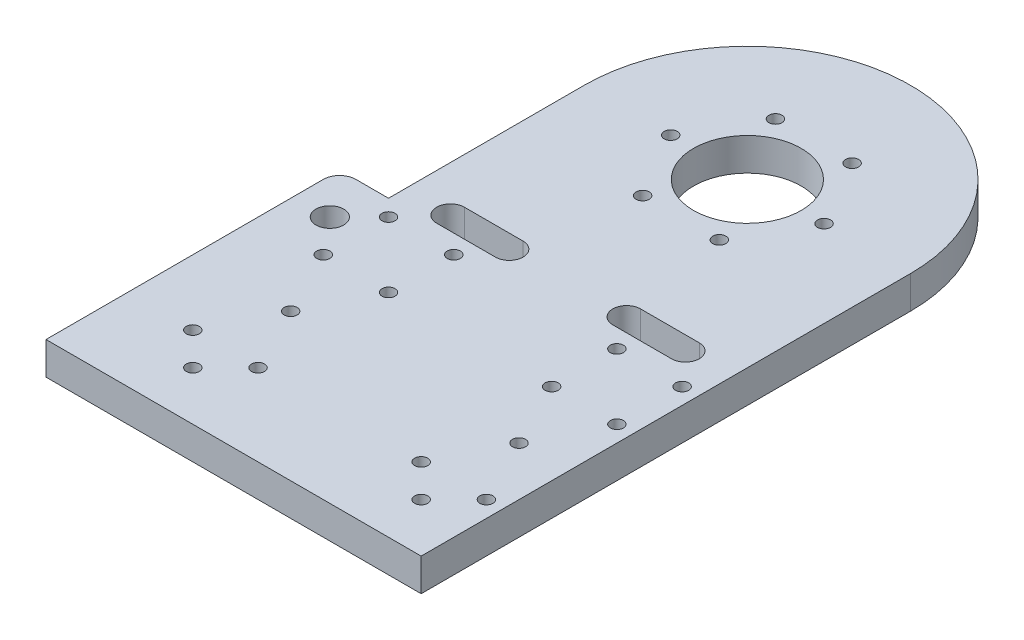
from build123d import *

# Parameters (mm, degrees)
SKETCH1_R           = 16.5
SKETCH1_R_2         = 2
BOSS_EXTRUDE3_DEPTH = 10
SKETCH9_W           = 90
SKETCH9_H           = 10
BOSS_EXTRUDE4_DEPTH = 15
FILLET1_R           = 5
SKETCH10_R          = 4.25
CUT_EXTRUDE7_DEPTH  = 10
CUT_EXTRUDE8_DEPTH  = 10


with BuildPart() as part:
    # Sketch1 → Boss-Extrude3 (new body)
    with BuildSketch(Plane(origin=(0, 0, 0), x_dir=(1, 0, 0), z_dir=(0, 1, 0))):
        with BuildLine():
            Line((-52.326392464, -141.880675109), (47.673607536, -141.880675109))
            Line((47.673607536, -141.880675109), (47.673607536, 8.119324891))
            ThreePointArc((47.673607536, 8.119324891), (-2.326392464, 58.119324891), (-52.326392464, 8.119324891))
            Line((-52.326392464, 8.119324891), (-52.326392464, -141.880675109))
        make_face()
        with Locations((-2.326392464, 8.119324891)):
            Circle(SKETCH1_R, mode=Mode.SUBTRACT)
        with Locations((21.173607536, 8.119324891)):
            Circle(SKETCH1_R_2, mode=Mode.SUBTRACT)
        with Locations((9.423607536, -12.232272098)):
            Circle(SKETCH1_R_2, mode=Mode.SUBTRACT)
        with Locations((-14.076392464, -12.232272098)):
            Circle(SKETCH1_R_2, mode=Mode.SUBTRACT)
        with Locations((-25.826392464, 8.119324891)):
            Circle(SKETCH1_R_2, mode=Mode.SUBTRACT)
        with Locations((-14.076392464, 28.47092188)):
            Circle(SKETCH1_R_2, mode=Mode.SUBTRACT)
        with Locations((9.423607536, 28.47092188)):
            Circle(SKETCH1_R_2, mode=Mode.SUBTRACT)
        with Locations((-47.326392464, -116.880675109)):
            Circle(SKETCH1_R_2, mode=Mode.SUBTRACT)
        with Locations((42.673607536, -116.880675109)):
            Circle(SKETCH1_R_2, mode=Mode.SUBTRACT)
        with Locations((-37.326392464, -126.880675109)):
            Circle(SKETCH1_R_2, mode=Mode.SUBTRACT)
        with Locations((-37.326392464, -96.880675109)):
            Circle(SKETCH1_R_2, mode=Mode.SUBTRACT)
        with Locations((-47.326392464, -76.880675109)):
            Circle(SKETCH1_R_2, mode=Mode.SUBTRACT)
        with Locations((42.673607536, -76.880675109)):
            Circle(SKETCH1_R_2, mode=Mode.SUBTRACT)
        with Locations((-47.326392464, -56.880675109)):
            Circle(SKETCH1_R_2, mode=Mode.SUBTRACT)
        with Locations((42.673607536, -56.880675109)):
            Circle(SKETCH1_R_2, mode=Mode.SUBTRACT)
        with Locations((-27.326392464, -116.880675109)):
            Circle(SKETCH1_R_2, mode=Mode.SUBTRACT)
        with Locations((22.673607536, -116.880675109)):
            Circle(SKETCH1_R_2, mode=Mode.SUBTRACT)
        with Locations((-27.326392464, -56.880675109)):
            Circle(SKETCH1_R_2, mode=Mode.SUBTRACT)
        with Locations((-27.326392464, -76.880675109)):
            Circle(SKETCH1_R_2, mode=Mode.SUBTRACT)
        with Locations((22.673607536, -56.880675109)):
            Circle(SKETCH1_R_2, mode=Mode.SUBTRACT)
        with Locations((22.673607536, -76.880675109)):
            Circle(SKETCH1_R_2, mode=Mode.SUBTRACT)
        with Locations((32.673607536, -96.880675109)):
            Circle(SKETCH1_R_2, mode=Mode.SUBTRACT)
        with Locations((32.673607536, -126.880675109)):
            Circle(SKETCH1_R_2, mode=Mode.SUBTRACT)
    extrude(amount=BOSS_EXTRUDE3_DEPTH)

    # Sketch9 → Boss-Extrude4 (add)
    with BuildSketch(Plane.ZY.offset(52.326392464)):
        with Locations((96.880675109, 5)):
            Rectangle(SKETCH9_W, SKETCH9_H)
    extrude(amount=BOSS_EXTRUDE4_DEPTH)

    # Fillet1
    fillet1_edges = [part.edges().sort_by_distance(p)[0] for p in [
        (-67.326392464, 5, 51.880675109),
    ]]
    fillet(fillet1_edges, radius=FILLET1_R)

    # Sketch10 → Cut-Extrude7 (cut)
    with BuildSketch(Plane(origin=(0, 10, 0), x_dir=(1, 0, 0), z_dir=(0, 1, 0))):
        with Locations((-56.326392464, -65.880675109)):
            Circle(SKETCH10_R)
    extrude(amount=-CUT_EXTRUDE7_DEPTH, mode=Mode.SUBTRACT)

    # Sketch11 → Cut-Extrude8 (cut)
    with BuildSketch(Plane(origin=(0, 10, 0), x_dir=(1, 0, 0), z_dir=(0, 1, 0))):
        with BuildLine():
            Line((15.673607536, -42.630675109), (33.673607536, -42.630675109))
            ThreePointArc((33.673607536, -42.630675109), (37.923607536, -46.880675109), (33.673607536, -51.130675109))
            Line((33.673607536, -51.130675109), (15.673607536, -51.130675109))
            ThreePointArc((15.673607536, -51.130675109), (11.423607536, -46.880675109), (15.673607536, -42.630675109))
        make_face()
        with BuildLine():
            Line((-38.326392464, -42.630675109), (-20.326392464, -42.630675109))
            ThreePointArc((-20.326392464, -42.630675109), (-16.076392464, -46.880675109), (-20.326392464, -51.130675109))
            Line((-20.326392464, -51.130675109), (-38.326392464, -51.130675109))
            ThreePointArc((-38.326392464, -51.130675109), (-42.576392464, -46.880675109), (-38.326392464, -42.630675109))
        make_face()
    extrude(amount=-CUT_EXTRUDE8_DEPTH, mode=Mode.SUBTRACT)


solid = part.part
